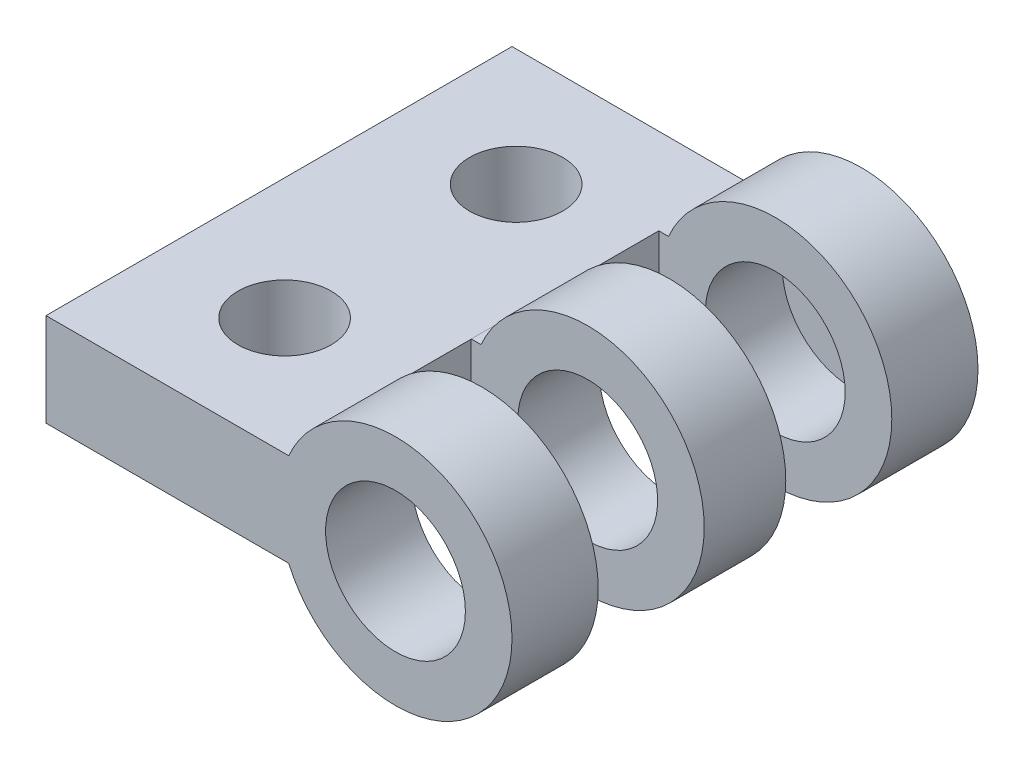
from build123d import *

# Parameters (mm, degrees)
SKETCH1_R                = 2.5
SKETCH1_R_2              = 1.5
BOSS_EXTRUDE2_DEPTH      = 1.95
BOSS_EXTRUDE3_DEPTH      = 1
BOSS_EXTRUDE3_DEPTH_BACK = 1
SKETCH7_W                = 5
SKETCH7_H                = 10
BOSS_EXTRUDE4_REACH      = 13.456
BOSS_EXTRUDE4_END_RADIUS = 2.5
SKETCH8_W                = 1.95
SKETCH8_H                = 2
SKETCH10_R               = 2.5
SKETCH10_R_2             = 1.5
BOSS_EXTRUDE5_DEPTH      = 1.95
BOSS_EXTRUDE6_DEPTH      = 0.975
BOSS_EXTRUDE6_DEPTH_BACK = 0.975
SKETCH12_R               = 2.5
SKETCH12_R_2             = 1.5
BOSS_EXTRUDE7_REACH      = 13.456
BOSS_EXTRUDE7_END_RADIUS = 2.5
SKETCH13_W               = 1.95
SKETCH13_H               = 2.002875352
SKETCH13_H_2             = 2
BOSS_EXTRUDE8_START      = -0.2
SKETCH15_R               = 1.5
BOSS_EXTRUDE8_DEPTH      = 0.2
SKETCH16_R               = 1
CUT_EXTRUDE1_DEPTH       = 10
SKETCH17_W               = 5
SKETCH17_H               = 5.480011174
CUT_EXTRUDE2_DEPTH       = 0.1
SKETCH18_W               = 5
SKETCH18_H               = 5.210920168
CUT_EXTRUDE3_DEPTH       = 0.1
SKETCH19_W               = 5
SKETCH19_H               = 5
CUT_EXTRUDE5_DEPTH       = 0.1
SKETCH20_W               = 5
SKETCH20_H               = 5.52517398
CUT_EXTRUDE6_DEPTH       = 0.1


with BuildPart() as part:
    # Sketch1 → Boss-Extrude2 (new body)
    with BuildSketch(Plane.XY):
        Circle(SKETCH1_R)
        Circle(SKETCH1_R_2, mode=Mode.SUBTRACT)
    extrude(amount=BOSS_EXTRUDE2_DEPTH)



with BuildPart() as body_2:
    # Sketch7 → Boss-Extrude3 (new, two sides: drawn at the far end of the back side and taken through both)
    with BuildSketch(Plane(origin=(0, 0, 0), x_dir=(1, 0, 0), z_dir=(0, 1, 0)).offset(-BOSS_EXTRUDE3_DEPTH_BACK)):
        with Locations((-5, -5)):
            Rectangle(SKETCH7_W, SKETCH7_H)
    extrude(amount=BOSS_EXTRUDE3_DEPTH + BOSS_EXTRUDE3_DEPTH_BACK)


with BuildPart() as part_1:
    add(part.part)

    add(body_2.part)  # Boss-Extrude4 merges body 2
    # Boss-Extrude4: up to this cylinder (the profile starts outside it)
    boss_extrude4_end = Plane(origin=(0, 0, 0.975), z_dir=(0, 0, -1)) * Cylinder(BOSS_EXTRUDE4_END_RADIUS, 32.912, mode=Mode.PRIVATE)
    # Sketch8 → Boss-Extrude4 (add, up to the surface)
    with BuildSketch(Plane(origin=(-2.5, 0, 0), x_dir=(0, 0, -1), z_dir=(1, 0, 0)), mode=Mode.PRIVATE) as boss_extrude4_sk1:
        with Locations((-0.975, 0)):
            Rectangle(SKETCH8_W, SKETCH8_H)
    boss_extrude4_tool1 = extrude(boss_extrude4_sk1.sketch, amount=BOSS_EXTRUDE4_REACH, mode=Mode.PRIVATE) - boss_extrude4_end
    add(boss_extrude4_tool1.solids().sort_by_distance((-2.5, 0, 0.975))[0])
    add(boss_extrude4_tool1.solids().sort_by_distance((-2.5, 0, 0.975))[1])



with BuildPart() as body_2_2:
    # Sketch10 → Boss-Extrude5 (new body)
    with BuildSketch(Plane.XY.offset(10)):
        Circle(SKETCH10_R)
        Circle(SKETCH10_R_2, mode=Mode.SUBTRACT)
    extrude(amount=-BOSS_EXTRUDE5_DEPTH)


with BuildPart() as body_3:
    # Sketch12 → Boss-Extrude6 (new, two sides: drawn at the far end of the back side and taken through both)
    with BuildSketch(Plane.YX.offset(-5).offset(-BOSS_EXTRUDE6_DEPTH_BACK)):
        Circle(SKETCH12_R)
        Circle(SKETCH12_R_2, mode=Mode.SUBTRACT)
    extrude(amount=BOSS_EXTRUDE6_DEPTH + BOSS_EXTRUDE6_DEPTH_BACK)


with BuildPart() as part_2:
    add(part_1.part)

    add(body_2_2.part)  # Boss-Extrude7 merges body 2 2

    add(body_3.part)  # Boss-Extrude7 merges body 3
    # Boss-Extrude7: up to this cylinder (the profile starts outside it)
    boss_extrude7_end = Plane(origin=(0, 0, 7.0125), z_dir=(0, 0, 1)) * Cylinder(BOSS_EXTRUDE7_END_RADIUS, 36.937, mode=Mode.PRIVATE)
    # Sketch13 → Boss-Extrude7 (add, up to the surface)
    with BuildSketch(Plane(origin=(-2.5, 0, 0), x_dir=(0, 0, -1), z_dir=(1, 0, 0)), mode=Mode.PRIVATE) as boss_extrude7_sk1:
        with Locations((-5, 0.001437676)):
            Rectangle(SKETCH13_W, SKETCH13_H)
    boss_extrude7_tool1 = extrude(boss_extrude7_sk1.sketch, amount=BOSS_EXTRUDE7_REACH, mode=Mode.PRIVATE) - boss_extrude7_end
    add(boss_extrude7_tool1.solids().sort_by_distance((-2.5, 0.001438, 5))[0])
    add(boss_extrude7_tool1.solids().sort_by_distance((-2.5, 0.001438, 5))[1])
    # Sketch13 → Boss-Extrude7 (add, up to the surface)
    with BuildSketch(Plane(origin=(-2.5, 0, 0), x_dir=(0, 0, -1), z_dir=(1, 0, 0)), mode=Mode.PRIVATE) as boss_extrude7_sk2:
        with Locations((-9.025, 0)):
            Rectangle(SKETCH13_W, SKETCH13_H_2)
    boss_extrude7_tool2 = extrude(boss_extrude7_sk2.sketch, amount=BOSS_EXTRUDE7_REACH, mode=Mode.PRIVATE) - boss_extrude7_end
    add(boss_extrude7_tool2.solids().sort_by_distance((-2.5, 0, 9.025))[0])
    add(boss_extrude7_tool2.solids().sort_by_distance((-2.5, 0, 9.025))[1])

    # Sketch15 → Boss-Extrude8 (add)
    with BuildSketch(Plane(origin=(0, 0, 0), x_dir=(-1, 0, 0), z_dir=(0, 0, -1)).offset(BOSS_EXTRUDE8_START)):
        Circle(SKETCH15_R)
    extrude(amount=BOSS_EXTRUDE8_DEPTH)

    # Sketch16 → Cut-Extrude1 (cut)
    with BuildSketch(Plane(origin=(0, 1, 0), x_dir=(1, 0, 0), z_dir=(0, 1, 0))):
        with Locations((-4.895643924, -7.484223199)):
            Circle(SKETCH16_R)
        with Locations((-4.895643924, -2.515776801)):
            Circle(SKETCH16_R)
    extrude(amount=-CUT_EXTRUDE1_DEPTH, mode=Mode.SUBTRACT)

    # Sketch17 → Cut-Extrude2 (cut)
    with BuildSketch(Plane(origin=(0, 0, 8.05), x_dir=(-1, 0, 0), z_dir=(0, 0, -1))):
        Rectangle(SKETCH17_W, SKETCH17_H)
    extrude(amount=-CUT_EXTRUDE2_DEPTH, mode=Mode.SUBTRACT)

    # Sketch18 → Cut-Extrude3 (cut)
    with BuildSketch(Plane.XY.offset(5.975)):
        Rectangle(SKETCH18_W, SKETCH18_H)
    extrude(amount=-CUT_EXTRUDE3_DEPTH, mode=Mode.SUBTRACT)

    # Sketch19 → Cut-Extrude5 (cut)
    with BuildSketch(Plane(origin=(0, 0, 4.025), x_dir=(-1, 0, 0), z_dir=(0, 0, -1))):
        Rectangle(SKETCH19_W, SKETCH19_H)
    extrude(amount=-CUT_EXTRUDE5_DEPTH, mode=Mode.SUBTRACT)

    # Sketch20 → Cut-Extrude6 (cut)
    with BuildSketch(Plane.XY.offset(1.95)):
        Rectangle(SKETCH20_W, SKETCH20_H)
    extrude(amount=-CUT_EXTRUDE6_DEPTH, mode=Mode.SUBTRACT)


solid = part_2.part
